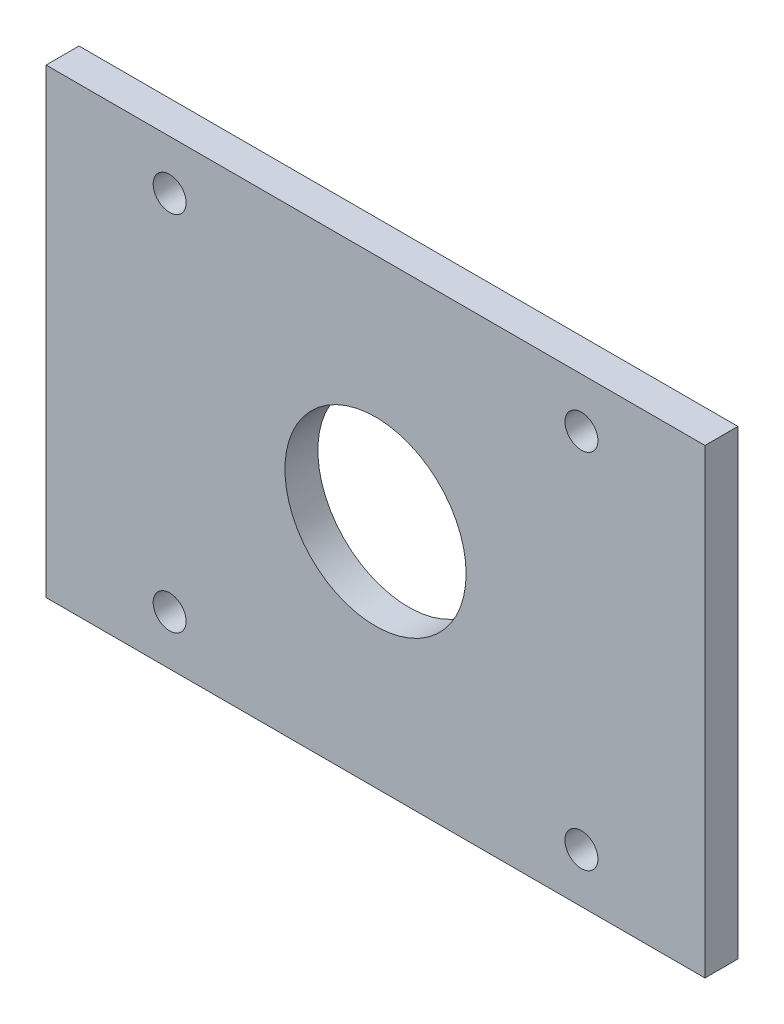
from build123d import *

# Parameters (mm, degrees)
SKETCH_1_W                  = 80
SKETCH_1_H                  = 56
SKETCH_1_R                  = 11
EXTRUDE_1_DEPTH             = 4
SKETCH_2_R                  = 2
CUT_EXTRUDE_1_DEPTH         = 100
PATTERN_LINEAR_1_COUNT      = 2
PATTERN_LINEAR_1_PITCH      = 44
PATTERN_LINEAR_1_COUNT_DIR2 = 2
PATTERN_LINEAR_1_PITCH_DIR2 = 50


with BuildPart() as part:
    # 草图1 → 凸台-拉伸1 (new body)
    with BuildSketch(Plane.XY):
        with Locations((0, 7)):
            Rectangle(SKETCH_1_W, SKETCH_1_H)
        with Locations((0, 7)):
            Circle(SKETCH_1_R, mode=Mode.SUBTRACT)
    extrude(amount=EXTRUDE_1_DEPTH)

    # 草图2 → 切除-拉伸1 (cut)
    with BuildSketch(Plane.XY.offset(4)):
        with Locations((-25, -15)):
            Circle(SKETCH_2_R)
    cut_extrude_1 = extrude(amount=-CUT_EXTRUDE_1_DEPTH, mode=Mode.SUBTRACT)

    # 阵列(线性)1: Cut-Extrude 1 2 × 2
    with Locations(*[(j * PATTERN_LINEAR_1_PITCH_DIR2, i * PATTERN_LINEAR_1_PITCH, 0) for i in range(PATTERN_LINEAR_1_COUNT) for j in range(PATTERN_LINEAR_1_COUNT_DIR2) if (i, j) != (0, 0)]):
        add(cut_extrude_1, mode=Mode.SUBTRACT)


solid = part.part
